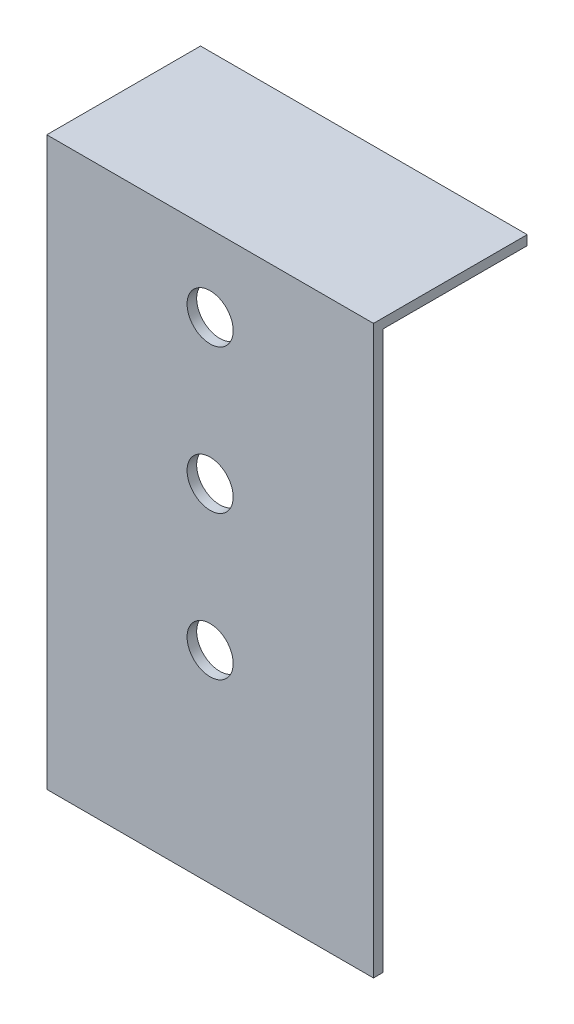
from build123d import *

# Parameters (mm, degrees)
SKETCH1_W           = 86.36
SKETCH1_H           = 2.54
BOSS_EXTRUDE1_DEPTH = 149.86
SKETCH2_W           = 86.36
SKETCH2_H           = 2.54
BOSS_EXTRUDE2_DEPTH = 38.1
SKETCH3_R           = 6.096
CUT_EXTRUDE1_DEPTH  = 41.64


with BuildPart() as part:
    # Sketch1 → Boss-Extrude1 (new body)
    with BuildSketch(Plane(origin=(0, 0, 0), x_dir=(1, 0, 0), z_dir=(0, 1, 0))):
        Rectangle(SKETCH1_W, SKETCH1_H)
    extrude(amount=BOSS_EXTRUDE1_DEPTH)

    # Sketch2 → Boss-Extrude2 (add)
    with BuildSketch(Plane(origin=(0, 0, -1.27), x_dir=(-1, 0, 0), z_dir=(0, 0, -1))):
        with Locations((0, 148.59)):
            Rectangle(SKETCH2_W, SKETCH2_H)
    extrude(amount=BOSS_EXTRUDE2_DEPTH)

    # Sketch3 → Cut-Extrude1 (cut, through all)
    with BuildSketch(Plane.XY.offset(1.27)):
        with Locations((0, 129.655411205)):
            Circle(SKETCH3_R)
        with Locations((0, 91.555411205)):
            Circle(SKETCH3_R)
        with Locations((0, 53.455411205)):
            Circle(SKETCH3_R)
    extrude(amount=-CUT_EXTRUDE1_DEPTH, mode=Mode.SUBTRACT)


solid = part.part
